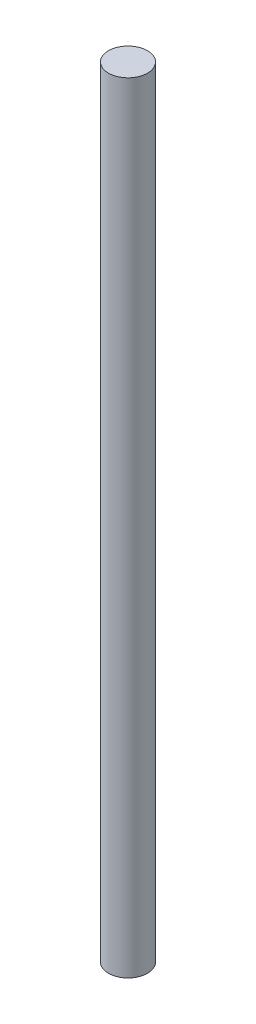
from build123d import *

# Parameters (mm, degrees)
SKETCH1_R           = 3.81
BOSS_EXTRUDE1_DEPTH = 76.2


with BuildPart() as part:
    # Sketch1 → Boss-Extrude1 (new body, symmetric)
    with BuildSketch(Plane(origin=(0, 0, 0), x_dir=(1, 0, 0), z_dir=(0, 1, 0))):
        Circle(SKETCH1_R)
    extrude(amount=BOSS_EXTRUDE1_DEPTH, both=True)


solid = part.part
